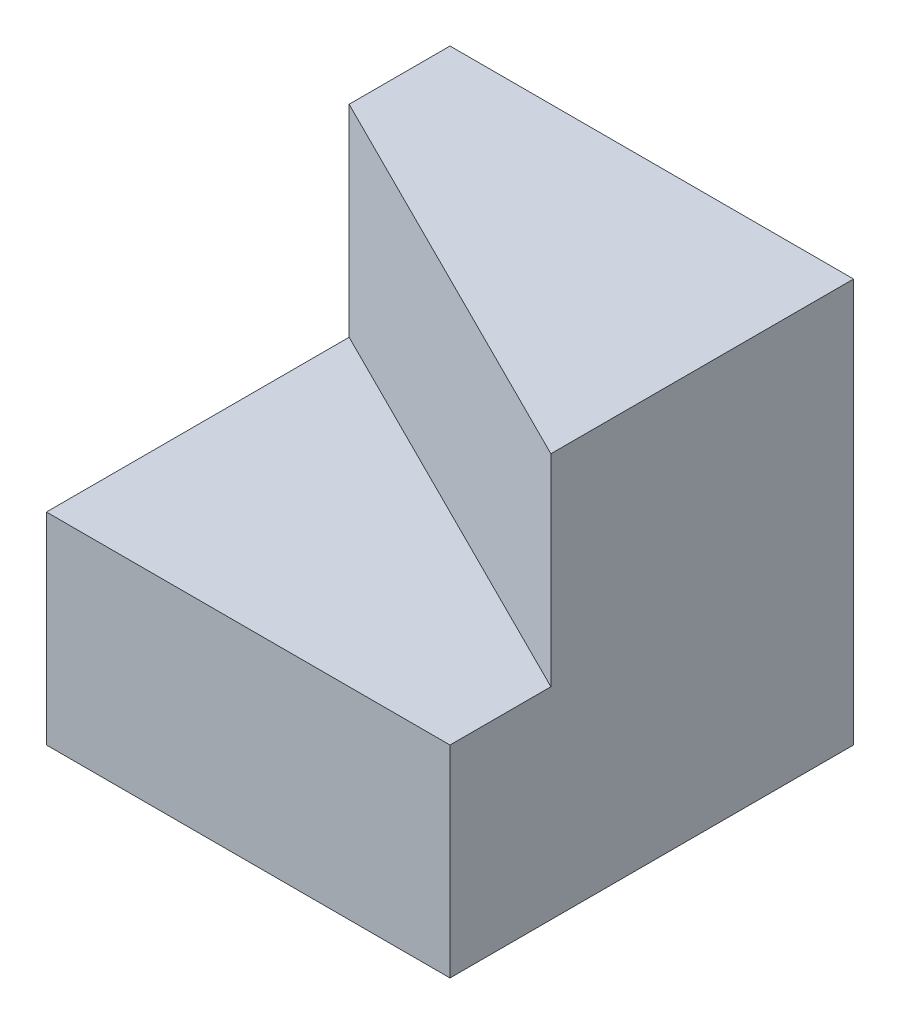
from build123d import *

# Parameters (mm, degrees)
SKETCH1_W           = 40
SKETCH1_H           = 40
BOSS_EXTRUDE1_DEPTH = 40
SKETCH2_W           = 10
SKETCH2_H           = 20
CUT_EXTRUDE1_DEPTH  = 40
CUT_EXTRUDE2_DEPTH  = 20
SKETCH4_W           = 40
SKETCH4_H           = 20
BOSS_EXTRUDE2_DEPTH = 10


with BuildPart() as part:
    # Sketch1 → Boss-Extrude1 (new body)
    with BuildSketch(Plane.XY):
        with Locations((20, 20)):
            Rectangle(SKETCH1_W, SKETCH1_H)
    extrude(amount=BOSS_EXTRUDE1_DEPTH)

    # Sketch2 → Cut-Extrude1 (cut)
    with BuildSketch(Plane.ZY):
        with Locations((5, 30)):
            Rectangle(SKETCH2_W, SKETCH2_H)
    extrude(amount=-CUT_EXTRUDE1_DEPTH, mode=Mode.SUBTRACT)

    # Sketch3 → Cut-Extrude2 (cut)
    with BuildSketch(Plane(origin=(0, 40, 0), x_dir=(1, 0, 0), z_dir=(0, 1, 0))):
        Polygon((40, -30), (0, -10), (0, -40), (40, -40), align=None)
    extrude(amount=-CUT_EXTRUDE2_DEPTH, mode=Mode.SUBTRACT)

    # Sketch4 → Boss-Extrude2 (add)
    with BuildSketch(Plane(origin=(0, 0, 0), x_dir=(-1, 0, 0), z_dir=(0, 0, -1))):
        with Locations((-20, 30)):
            Rectangle(SKETCH4_W, SKETCH4_H)
    extrude(amount=-BOSS_EXTRUDE2_DEPTH)


solid = part.part
